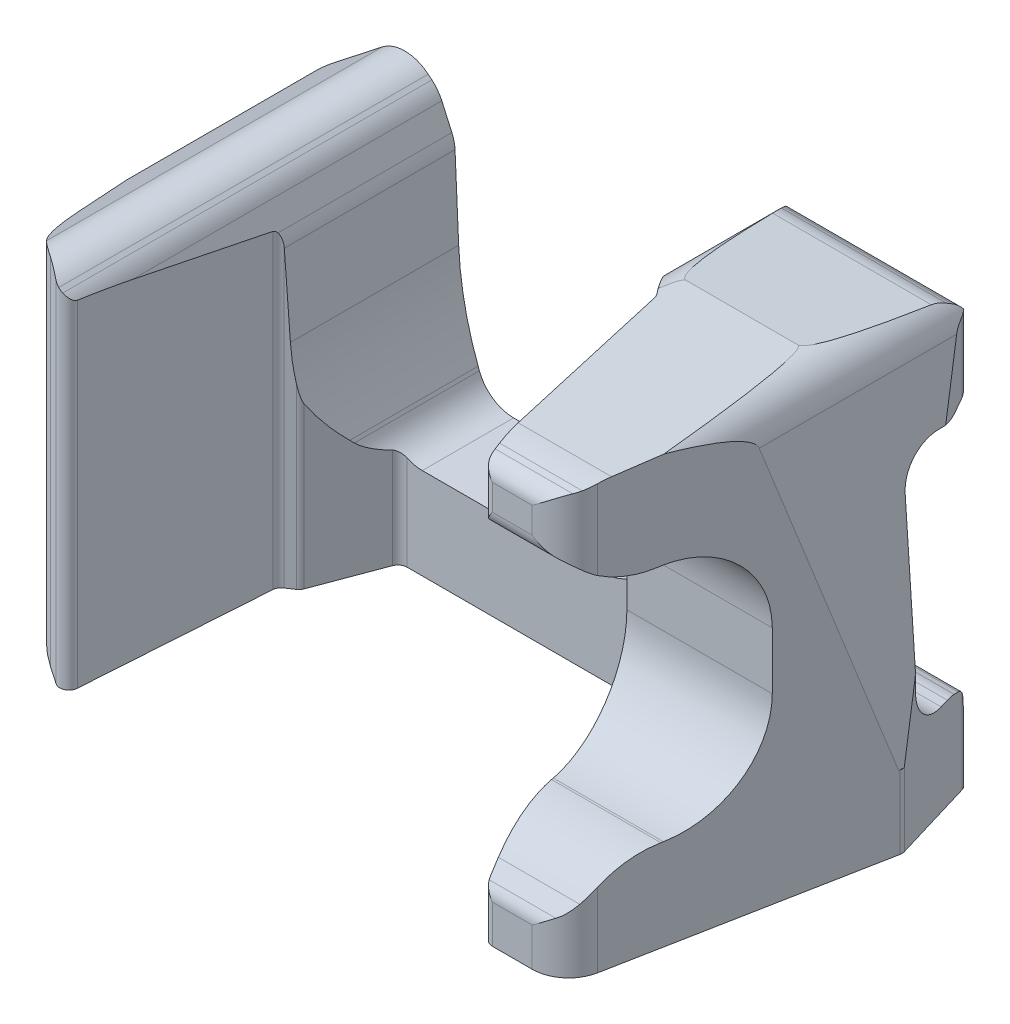
from build123d import *

# Parameters (mm, degrees)
BOSS_EXTRUDE1_DEPTH = 47.5
CUT_EXTRUDE1_DEPTH  = 41.3
CUT_EXTRUDE2_DEPTH  = 40.5


with BuildPart() as part:
    # Sketch2 → Boss-Extrude1 (new body)
    with BuildSketch(Plane(origin=(0, 0, 0), x_dir=(1, 0, 0), z_dir=(0, 1, 0))):
        with BuildLine():
            Line((-32.552469583, 10), (36.159469115, 10))
            ThreePointArc((36.159469115, 10), (36.756399645, 9.802292928), (37.1172954, 9.287347886))
            Line((37.1172954, 9.287347886), (39.833051104, 0.234828872))
            ThreePointArc((39.833051104, 0.234828872), (39.873923044, -0.001510627), (39.857342997, -0.240784479))
            Line((39.857342997, -0.240784479), (34.525916023, -28.053061861))
            ThreePointArc((34.525916023, -28.053061861), (33.145751826, -30.38320024), (30.597443313, -31.3))
            Line((30.597443313, -31.3), (26.228846161, -31.3))
            ThreePointArc((26.228846161, -31.3), (25.592304258, -31.071242119), (25.246990309, -30.489628813))
            Line((25.246990309, -30.489628813), (20.947172323, -8.226126794))
            ThreePointArc((20.947172323, -8.226126794), (20.879566818, -8.010605878), (20.765316471, -7.815755607))
            Line((20.765316471, -7.815755607), (15.203499766, -0.4))
            ThreePointArc((15.203499766, -0.4), (14.850713361, -0.105572809), (14.403499766, 0))
            Line((14.403499766, 0), (-14.403499766, 0))
            ThreePointArc((-14.403499766, 0), (-14.973094604, -0.178074382), (-15.339828943, -0.648876558))
            Line((-15.339828943, -0.648876558), (-17.983246468, -7.697989958))
            ThreePointArc((-17.983246468, -7.697989958), (-18.136239953, -7.968465416), (-18.364875449, -8.17891681))
            Line((-18.364875449, -8.17891681), (-19.186523629, -8.726682264))
            ThreePointArc((-19.186523629, -8.726682264), (-19.497158119, -9.057538104), (-19.62956882, -9.49161964))
            Line((-19.62956882, -9.49161964), (-20.978947277, -29.552379372))
            ThreePointArc((-20.978947277, -29.552379372), (-21.540290052, -30.385017954), (-22.541698043, -30.310353674))
            Line((-22.541698043, -30.310353674), (-24.58040313, -28.914283886))
            ThreePointArc((-24.58040313, -28.914283886), (-29.236292427, -24.270070846), (-31.913277739, -18.263427062))
            Line((-31.913277739, -18.263427062), (-36.233542352, -0.262324509))
            ThreePointArc((-36.233542352, -0.262324509), (-36.260764309, -0.000999291), (-36.218981335, 0.258396329))
            Line((-36.218981335, 0.258396329), (-33.510295868, 9.287347886))
            ThreePointArc((-33.510295868, 9.287347886), (-33.149400113, 9.802292928), (-32.552469583, 10))
        make_face()
    extrude(amount=BOSS_EXTRUDE1_DEPTH)

    # Sketch3 → Cut-Extrude1 (cut)
    with BuildSketch(Plane(origin=(0, 0, -10), x_dir=(-1, 0, 0), z_dir=(0, 0, -1))):
        with BuildLine():
            Line((32.552469583, 47.5), (-21.168110219, 47.5))
            ThreePointArc((-21.168110219, 47.5), (-18.321887432, 46.310518786), (-17.168428913, 43.449507924))
            Line((-17.168428913, 43.449507924), (-17.409870927, 24.323910618))
            ThreePointArc((-17.409870927, 24.323910618), (-16.305213355, 18.481896044), (-13.017667747, 13.527963616))
            Line((-13.017667747, 13.527963616), (-12.125743101, 12.636038969))
            ThreePointArc((-12.125743101, 12.636038969), (-9.205932962, 10.685084207), (-5.76178207, 10))
            Line((-5.76178207, 10), (12.738293996, 10))
            ThreePointArc((12.738293996, 10), (15.016673347, 10.71229753), (16.483610706, 12.595506234))
            Line((16.483610706, 12.595506234), (16.622163055, 12.964979165))
            ThreePointArc((16.622163055, 12.964979165), (18.096265428, 18.084752173), (18.752473248, 23.371948477))
            Line((18.752473248, 23.371948477), (19.152230627, 32.2393169))
            ThreePointArc((19.152230627, 32.2393169), (19.256411736, 32.983402703), (19.497903243, 33.694879504))
            Line((19.497903243, 33.694879504), (20.600286189, 36.15497413))
            ThreePointArc((20.600286189, 36.15497413), (21.063238155, 36.936085506), (21.690428475, 37.592661324))
            Line((21.690428475, 37.592661324), (22.096653464, 37.931045304))
            ThreePointArc((22.096653464, 37.931045304), (24.597376449, 38.857209949), (27.124502072, 38.005721556))
            Line((27.124502072, 38.005721556), (32.552469583, 33.750824696))
            Line((32.552469583, 33.750824696), (32.552469583, 47.5))
        make_face()
        with BuildLine():
            Line((-40.723201367, 8), (-39.833051104, 8))
            Line((-39.833051104, 8), (-37.373445098, 43.774365535))
            ThreePointArc((-37.373445098, 43.774365535), (-37.008487788, 45.189634522), (-36.159469115, 46.379318277))
            Line((-36.159469115, 46.379318277), (-36.159469115, 47.5))
            Line((-36.159469115, 47.5), (-33.382865747, 47.5))
            Line((-33.382865747, 47.5), (-21.168110219, 47.5))
            Line((-21.168110219, 47.5), (32.552469583, 47.5))
            Line((32.552469583, 47.5), (32.552469583, 33.750824696))
            Line((32.552469583, 33.750824696), (33.510295868, 33))
            Line((33.510295868, 33), (36.218981335, 8))
            Line((36.218981335, 8), (36.821846002, 8))
            Line((36.821846002, 8), (36.821846002, 48.325130401))
            Line((36.821846002, 48.325130401), (-40.723201367, 48.325130401))
            Line((-40.723201367, 48.325130401), (-40.723201367, 8))
        make_face()
        with BuildLine():
            Line((-40.723201367, 8), (-39.833051104, 8))
            Line((-39.833051104, 8), (-37.373445098, 43.774365535))
            ThreePointArc((-37.373445098, 43.774365535), (-37.008487788, 45.189634522), (-36.159469115, 46.379318277))
            Line((-36.159469115, 46.379318277), (-36.159469115, 47.5))
            Line((-36.159469115, 47.5), (-33.382865747, 47.5))
            Line((-33.382865747, 47.5), (-21.168110219, 47.5))
            Line((-21.168110219, 47.5), (32.552469583, 47.5))
            Line((32.552469583, 47.5), (32.552469583, 33.750824696))
            Line((32.552469583, 33.750824696), (33.510295868, 33))
            Line((33.510295868, 33), (36.218981335, 8))
            Line((36.218981335, 8), (36.821846002, 8))
            Line((36.821846002, 8), (36.821846002, 48.325130401))
            Line((36.821846002, 48.325130401), (-40.723201367, 48.325130401))
            Line((-40.723201367, 48.325130401), (-40.723201367, 8))
        make_face()
        with BuildLine():
            Line((-36.159469115, 47.5), (-36.159469115, 46.379318277))
            ThreePointArc((-36.159469115, 46.379318277), (-34.879984128, 47.209263613), (-33.382865747, 47.5))
            Line((-33.382865747, 47.5), (-36.159469115, 47.5))
        make_face()
    extrude(amount=-CUT_EXTRUDE1_DEPTH, mode=Mode.SUBTRACT)

    # Sketch4 → Cut-Extrude2 (cut)
    with BuildSketch(Plane(origin=(0, 0, 0), x_dir=(0, 0, -1), z_dir=(1, 0, 0))):
        with BuildLine():
            Line((-31.3, 4.195379425), (-31.3, 0))
            Line((-31.3, 0), (-32.3, 0))
            Line((-32.3, 0), (-32.3, 47.5))
            Line((-32.3, 47.5), (-5, 47.5))
            Line((-5, 47.5), (-26.770215318, 46.555647556))
            ThreePointArc((-26.770215318, 46.555647556), (-28.039085995, 46.419095708), (-29.280232562, 46.122052947))
            Line((-29.280232562, 46.122052947), (-29.888678312, 45.934662327))
            ThreePointArc((-29.888678312, 45.934662327), (-30.908937013, 45.211250874), (-31.3, 44.023260265))
            Line((-31.3, 44.023260265), (-31.3, 41.187475863))
            ThreePointArc((-31.3, 41.187475863), (-31.111178842, 40.339165071), (-30.580368799, 39.651033304))
            Line((-30.580368799, 39.651033304), (-29.281344645, 38.568513175))
            ThreePointArc((-29.281344645, 38.568513175), (-26.283753286, 36.848010194), (-22.879500648, 36.250725971))
            Line((-22.879500648, 36.250725971), (-22, 36.250725971))
            ThreePointArc((-22, 36.250725971), (-14.928932188, 33.321793783), (-12, 26.250725971))
            Line((-12, 26.250725971), (-12, 20))
            ThreePointArc((-12, 20), (-14.928932188, 12.928932188), (-22, 10))
            Line((-22, 10), (-22.237821239, 10))
            ThreePointArc((-22.237821239, 10), (-26.15871509, 9.199271243), (-29.451694449, 6.925318282))
            Line((-29.451694449, 6.925318282), (-30.742774642, 5.580443081))
            ThreePointArc((-30.742774642, 5.580443081), (-31.155471542, 4.941854714), (-31.3, 4.195379425))
        make_face()
        with BuildLine():
            ThreePointArc((10, 4.607407262), (9.984657997, 4.998795368), (9.93872614, 5.387781603))
            Line((9.93872614, 5.387781603), (9.387700351, 8.875038075))
            ThreePointArc((9.387700351, 8.875038075), (9.146370303, 9.384443769), (8.66787851, 9.682403427))
            Line((8.66787851, 9.682403427), (8.051684955, 9.853760882))
            ThreePointArc((8.051684955, 9.853760882), (7.520803976, 9.963271599), (6.979991406, 10))
            Line((6.979991406, 10), (6, 10))
            ThreePointArc((6, 10), (3.171572875, 11.171572875), (2, 14))
            Line((2, 14), (2, 32.250725971))
            ThreePointArc((2, 32.250725971), (3.171572875, 35.079153096), (6, 36.250725971))
            Line((6, 36.250725971), (7.168973425, 36.250725971))
            ThreePointArc((7.168973425, 36.250725971), (7.722438734, 36.328832074), (8.232675024, 36.557049819))
            Line((8.232675024, 36.557049819), (9.063701599, 37.078970315))
            ThreePointArc((9.063701599, 37.078970315), (9.75034328, 37.805021333), (10, 38.772646467))
            Line((10, 38.772646467), (10, 44.19906664))
            ThreePointArc((10, 44.19906664), (9.676529629, 45.289593302), (8.810751599, 46.027366901))
            Line((8.810751599, 46.027366901), (8.370895198, 46.22241926))
            ThreePointArc((8.370895198, 46.22241926), (7.730657447, 46.443591053), (7.0622806, 46.553562552))
            Line((7.0622806, 46.553562552), (-5, 47.5))
            Line((-5, 47.5), (11, 47.5))
            Line((11, 47.5), (11, 0))
            Line((11, 0), (10, 0))
            Line((10, 0), (10, 4.607407262))
        make_face()
    extrude(amount=CUT_EXTRUDE2_DEPTH, mode=Mode.SUBTRACT)


solid = part.part
